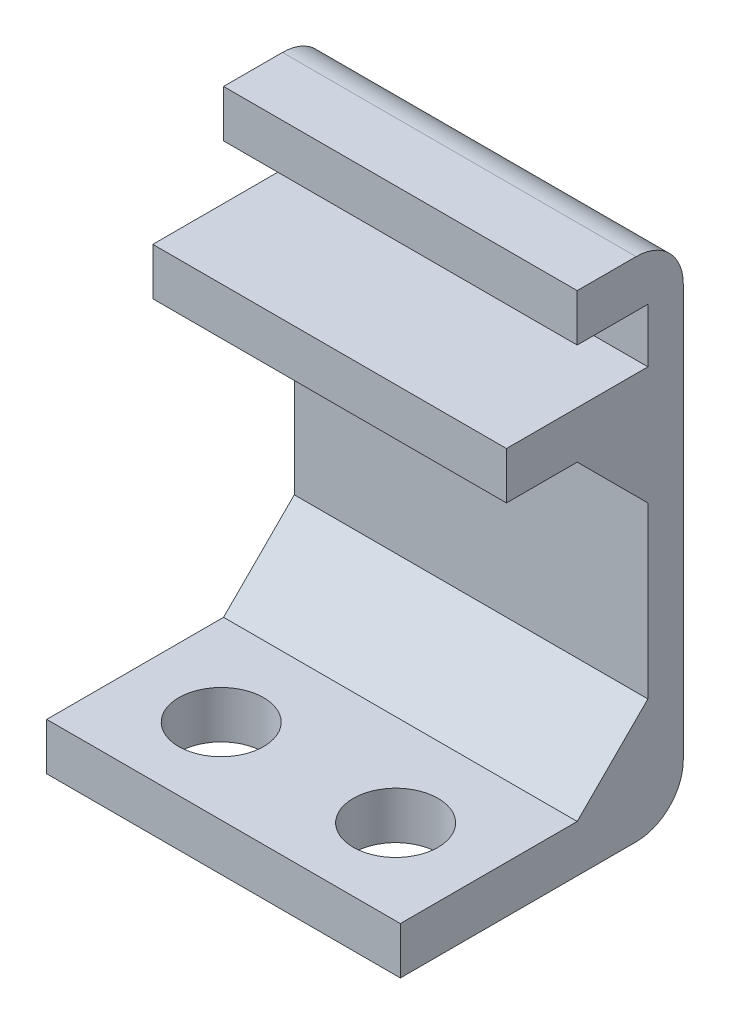
from build123d import *

# Parameters (mm, degrees)
BOSS_EXTRUDE1_DEPTH     = 7.5
CHAMFER1_SIZE           = 3
SKETCH2_R               = 1.8
CUT_EXTRUDE1_DEPTH      = 3
CUT_EXTRUDE1_DEPTH_BACK = 3
FILLET1_R               = 2


with BuildPart() as part:
    # Sketch1 → Boss-Extrude1 (new body, symmetric)
    with BuildSketch(Plane(origin=(0, 0, 0), x_dir=(0, 0, -1), z_dir=(1, 0, 0))):
        Polygon((-5.25, -8.75), (-5.25, -10.75), (6.75, -10.75), (6.75, 10.75), (2.25, 10.75), (2.25, 8.75), (5.25, 8.75), (5.25, 6.45), (-0.75, 6.45), (-0.75, 4.45), (5.25, 4.45), (5.25, -8.75), align=None)
    extrude(amount=BOSS_EXTRUDE1_DEPTH, both=True)

    # Chamfer1
    chamfer1_edges = [part.edges().sort_by_distance(p)[0] for p in [
        (0, -8.75, -5.25),
        (0, 4.45, -5.25),
    ]]
    chamfer(chamfer1_edges, length=CHAMFER1_SIZE)

    # Sketch2 → Cut-Extrude1 (cut, two sides)
    with BuildSketch(Plane(origin=(0, -8.75, 0), x_dir=(1, 0, 0), z_dir=(0, 1, 0))) as cut_extrude1_sk:
        with Locations((-3.7, -1.65)):
            Circle(SKETCH2_R)
        with Locations((3.7, -1.65)):
            Circle(SKETCH2_R)
    extrude(amount=CUT_EXTRUDE1_DEPTH, mode=Mode.SUBTRACT)
    extrude(cut_extrude1_sk.sketch, amount=-CUT_EXTRUDE1_DEPTH_BACK, mode=Mode.SUBTRACT)

    # Fillet1
    fillet1_edges = [part.edges().sort_by_distance(p)[0] for p in [
        (0, 10.75, -6.75),
        (0, -10.75, -6.75),
    ]]
    fillet(fillet1_edges, radius=FILLET1_R)


solid = part.part
